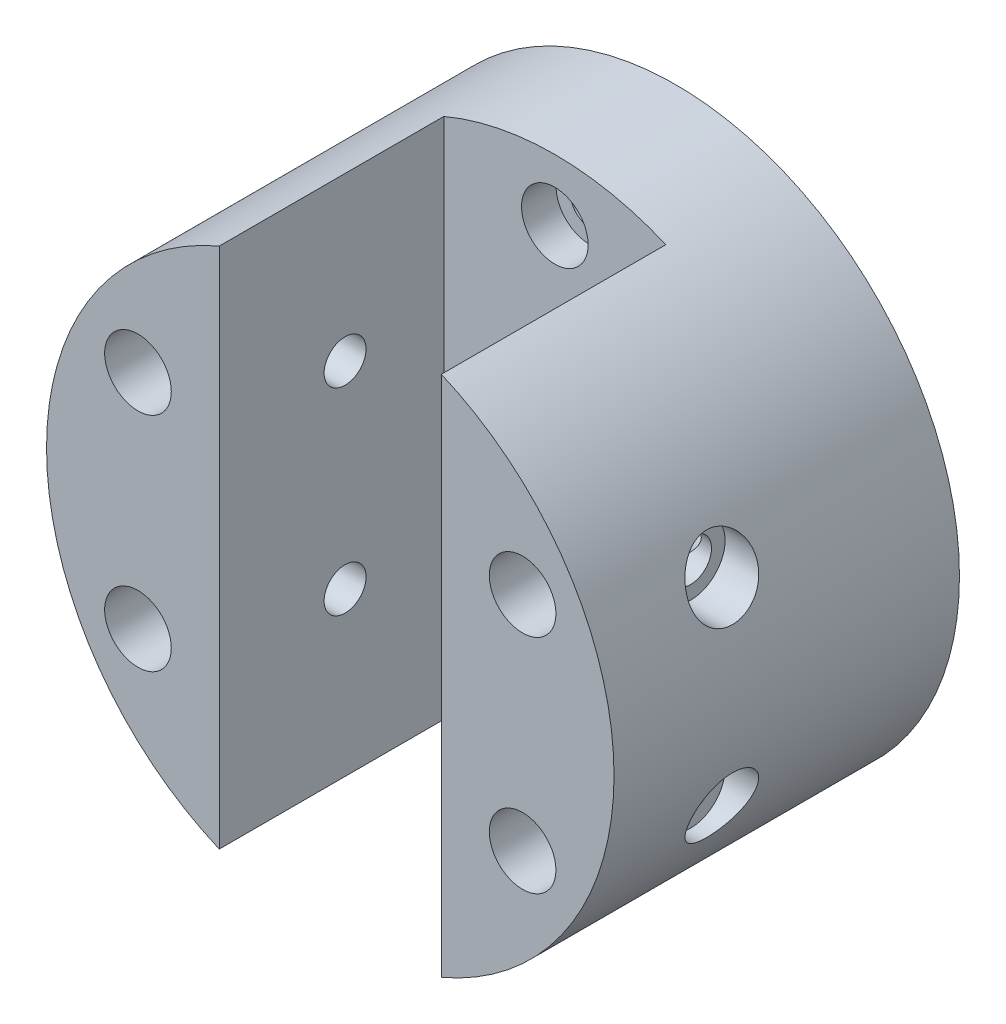
from build123d import *

# Parameters (mm, degrees)
SKETCH_1_R               = 23
EXTRUDE_1_DEPTH          = 28
CUT_EXTRUDE_1_DEPTH      = 18.2
SKETCH_3_R               = 1.5
CUT_EXTRUDE_2_DEPTH      = 29
SKETCH_5_R               = 2.7
CUT_EXTRUDE_3_DEPTH      = 21
SKETCH_7_R               = 1.7
CUT_EXTRUDE_4_DEPTH      = 33
CUT_EXTRUDE_4_DEPTH_BACK = 15
SKETCH_8_R               = 2.8
CUT_EXTRUDE_5_DEPTH      = 4


with BuildPart() as part:
    # 草图1 → 凸台-拉伸1 (new body)
    with BuildSketch(Plane.XY):
        Circle(SKETCH_1_R)
    extrude(amount=EXTRUDE_1_DEPTH)

    # 草图2 → 切除-拉伸1 (cut)
    with BuildSketch(Plane.XY.offset(28)):
        with BuildLine():
            ThreePointArc((9, 21.166010489), (0, 23), (-9, 21.166010489))
            Line((-9, 21.166010489), (-9, -21.166010489))
            ThreePointArc((-9, -21.166010489), (0, -23), (9, -21.166010489))
            Line((9, -21.166010489), (9, 21.166010489))
        make_face()
    extrude(amount=-CUT_EXTRUDE_1_DEPTH, mode=Mode.SUBTRACT)

    # 草图3 → 切除-拉伸2 (cut, through all)
    with BuildSketch(Plane.XY.offset(28)):
        with Locations((0, 18)):
            Circle(SKETCH_3_R)
        with Locations((15.588457268, 9)):
            Circle(SKETCH_3_R)
        with Locations((15.588457268, -9)):
            Circle(SKETCH_3_R)
        with Locations((0, -18)):
            Circle(SKETCH_3_R)
        with Locations((-15.588457268, -9)):
            Circle(SKETCH_3_R)
        with Locations((-15.588457268, 9)):
            Circle(SKETCH_3_R)
    extrude(amount=-CUT_EXTRUDE_2_DEPTH, mode=Mode.SUBTRACT)

    # 草图5 → 切除-拉伸3 (cut)
    with BuildSketch(Plane.XY.offset(28)):
        with Locations((0, 18)):
            Circle(SKETCH_5_R)
        with Locations((15.588457268, 9)):
            Circle(SKETCH_5_R)
        with Locations((15.588457268, -9)):
            Circle(SKETCH_5_R)
        with Locations((0, -18)):
            Circle(SKETCH_5_R)
        with Locations((-15.588457268, -9)):
            Circle(SKETCH_5_R)
        with Locations((-15.588457268, 9)):
            Circle(SKETCH_5_R)
    extrude(amount=-CUT_EXTRUDE_3_DEPTH, mode=Mode.SUBTRACT)

    # 草图7 → 切除-拉伸4 (cut, two sides)
    with BuildSketch(Plane.ZY.offset(-9)) as cut_extrude_4_sk:
        with Locations((17.8, 8)):
            Circle(SKETCH_7_R)
        with Locations((17.8, -8)):
            Circle(SKETCH_7_R)
    extrude(amount=CUT_EXTRUDE_4_DEPTH, mode=Mode.SUBTRACT)
    extrude(cut_extrude_4_sk.sketch, amount=-CUT_EXTRUDE_4_DEPTH_BACK, mode=Mode.SUBTRACT)

    # 草图8 → 切除-拉伸5 (cut)
    with BuildSketch(Plane.ZY.offset(-23)):
        with Locations((17.8, 8)):
            Circle(SKETCH_8_R)
        with Locations((17.8, -8)):
            Circle(SKETCH_8_R)
    extrude(amount=CUT_EXTRUDE_5_DEPTH, mode=Mode.SUBTRACT)


solid = part.part
